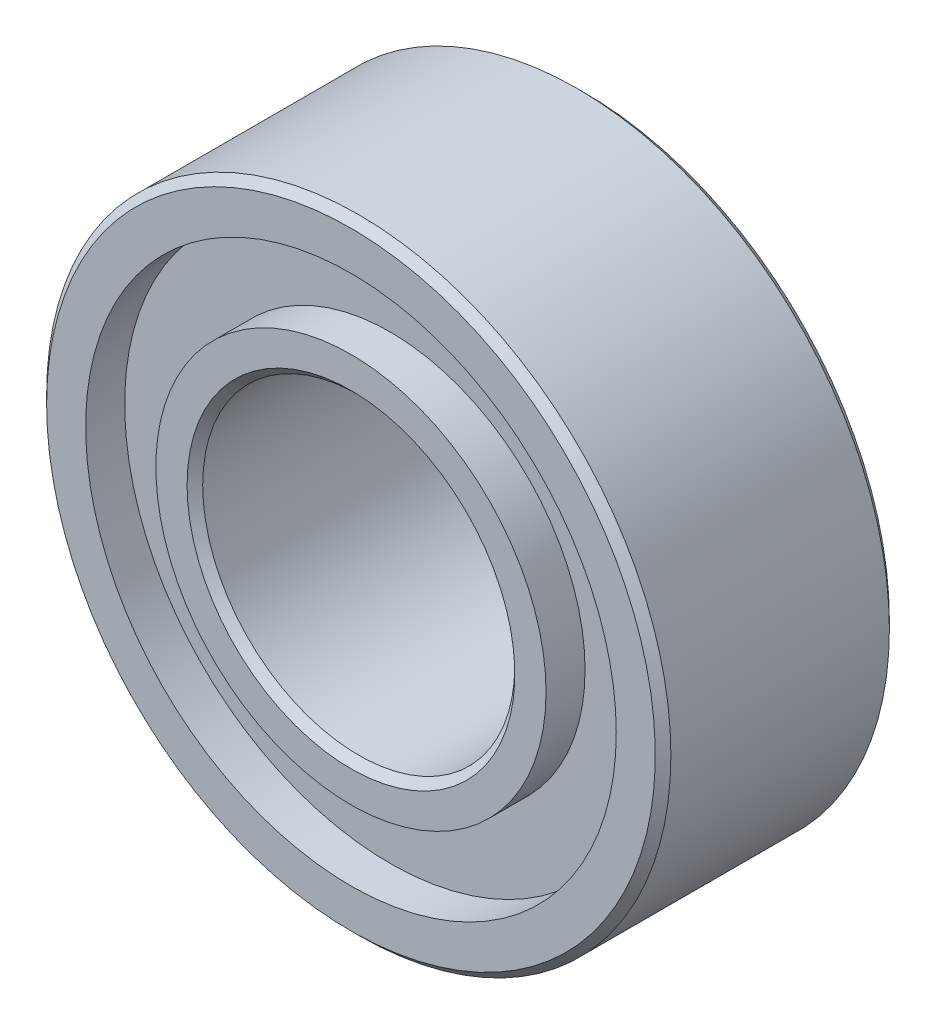
from build123d import *

# Parameters (mm, degrees)
FASE1_SIZE = 0.1


with BuildPart() as part:
    # Skizze2 → Rotation1 (revolve)
    with BuildSketch(Plane(origin=(0, 0, 0), x_dir=(0, 0, -1), z_dir=(1, 0, 0))):
        Polygon((-1.5, 2), (1.5, 2), (1.5, 2.5), (1, 2.5), (1, 3.4), (1.5, 3.4), (1.5, 4), (-1.5, 4), (-1.5, 3.4), (-1, 3.4), (-1, 2.5), (-1.5, 2.5), align=None)
    revolve(axis=Axis((0, 0, 11.845846522), (0, 0, -1)))

    # Fase1
    fase1_edges = [part.edges().sort_by_distance(p)[0] for p in [
        (0, -2, -1.5),
        (0, -2, 1.5),
        (0, -4, -1.5),
        (0, -4, 1.5),
    ]]
    chamfer(fase1_edges, length=FASE1_SIZE)


solid = part.part
